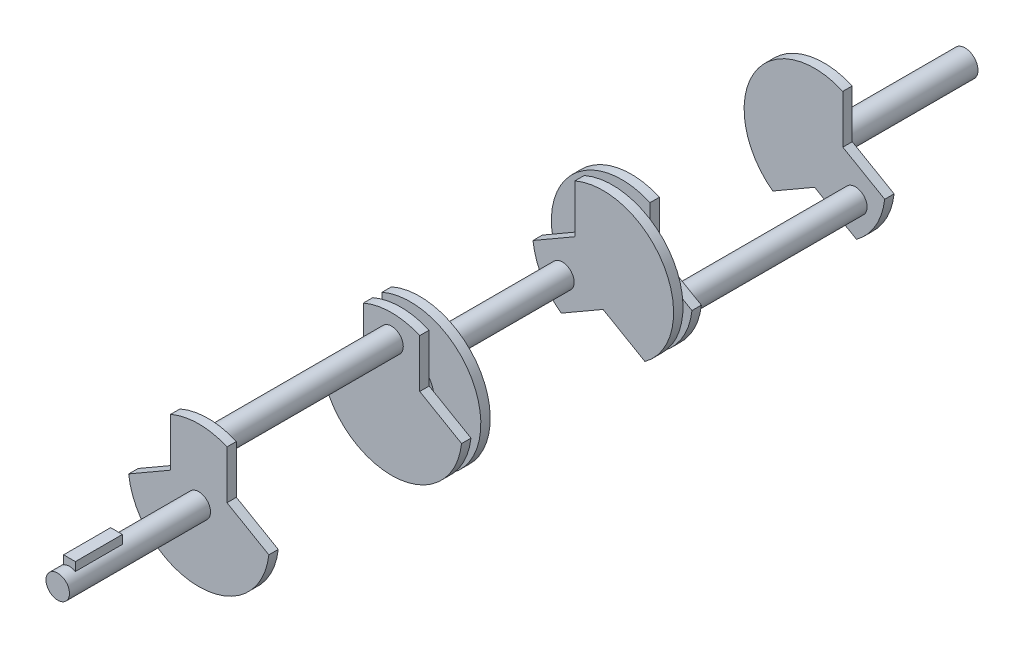
from build123d import *

# Parameters (mm, degrees)
BOSS_EXTRUDE1_DEPTH   = 5.08
LPATTERN1_COUNT       = 2
LPATTERN1_PITCH       = 104.14
SKETCH2_R             = 6.35
BOSS_EXTRUDE2_DEPTH   = 104.14
LPATTERN2_COUNT       = 3
LPATTERN2_PITCH       = 114.3
BODY_MOVE_COPY1_ANGLE = 120
BODY_MOVE_COPY2_ANGLE = 120
SKETCH3_R             = 12.7
BOSS_EXTRUDE3_DEPTH   = 5.08
BOSS_EXTRUDE4_START   = 114.3
SKETCH3_2_R           = 12.7
BOSS_EXTRUDE4_DEPTH   = 5.08
SKETCH4_R             = 6.985
BOSS_EXTRUDE5_DEPTH   = 76.2
SKETCH5_R             = 6.35
BOSS_EXTRUDE6_DEPTH   = 76.2
BOSS_EXTRUDE7_START   = 5.499261
SKETCH6_W             = 6.35
SKETCH6_H             = 25.4
BOSS_EXTRUDE7_DEPTH   = 4.660739


with BuildPart() as part:
    # Sketch1 → Boss-Extrude1 (new body)
    with BuildSketch(Plane.XY):
        with BuildLine():
            Line((15.24, 8.798818102), (15.24, 34.919226796))
            ThreePointArc((15.24, 34.919226796), (0, 38.1), (-15.24, 34.919226796))
            Line((-15.24, 34.919226796), (-15.24, 8.798818102))
            Line((-15.24, 8.798818102), (-37.860937485, -4.261386244))
            ThreePointArc((-37.860937485, -4.261386244), (0, -38.1), (37.860937485, -4.261386244))
            Line((37.860937485, -4.261386244), (15.24, 8.798818102))
        make_face()
    extrude(amount=-BOSS_EXTRUDE1_DEPTH)


with BuildPart() as lpattern1_1:
    # LPattern1: pattern copy
    add(part.part.moved(Location(Vector(0, 0, -1) * (1 * LPATTERN1_PITCH))))


with BuildPart() as part_1:
    add(part.part)

    add(lpattern1_1.part)  # Boss-Extrude2 merges LPattern1_1
    # Sketch2 → Boss-Extrude2 (add)
    with BuildSketch(Plane(origin=(0, 0, -5.08), x_dir=(-1, 0, 0), z_dir=(0, 0, -1))):
        with Locations((0, 25.4)):
            Circle(SKETCH2_R)
    extrude(amount=BOSS_EXTRUDE2_DEPTH)


with BuildPart() as lpattern2_1:
    # LPattern2: pattern copy
    add(part_1.part.moved(Location(Vector(0, 0, -1) * (1 * LPATTERN2_PITCH))))


with BuildPart() as lpattern2_2:
    # LPattern2: pattern copy
    add(part_1.part.moved(Location(Vector(0, 0, -1) * (2 * LPATTERN2_PITCH))))


with BuildPart() as lpattern2_1_1:
    # Body-Move_Copy1: moved
    add(lpattern2_1.part.rotate(Axis((0, 0, 0), (0, 0, 1)), BODY_MOVE_COPY1_ANGLE))


with BuildPart() as lpattern2_2_1:
    # Body-Move_Copy2: moved
    add(lpattern2_2.part.rotate(Axis((0, 0, 0), (0, 0, -1)), BODY_MOVE_COPY2_ANGLE))


with BuildPart() as part_2:
    add(part_1.part)

    add(lpattern2_1_1.part)  # Boss-Extrude3 merges LPattern2_1
    # Sketch3 → Boss-Extrude3 (add)
    with BuildSketch(Plane(origin=(0, 0, -109.22), x_dir=(-1, 0, 0), z_dir=(0, 0, -1))):
        Circle(SKETCH3_R)
    extrude(amount=BOSS_EXTRUDE3_DEPTH)

    add(lpattern2_2_1.part)  # Boss-Extrude4 merges LPattern2_2
    # Sketch3_2 → Boss-Extrude4 (add)
    with BuildSketch(Plane(origin=(0, 0, -109.22), x_dir=(-1, 0, 0), z_dir=(0, 0, -1)).offset(BOSS_EXTRUDE4_START)):
        Circle(SKETCH3_2_R)
    extrude(amount=BOSS_EXTRUDE4_DEPTH)

    # Sketch4 → Boss-Extrude5 (add)
    with BuildSketch(Plane(origin=(0, 0, -337.82), x_dir=(-1, 0, 0), z_dir=(0, 0, -1))):
        Circle(SKETCH4_R)
    extrude(amount=BOSS_EXTRUDE5_DEPTH)

    # Sketch5 → Boss-Extrude6 (add)
    with BuildSketch(Plane.XY):
        Circle(SKETCH5_R)
    extrude(amount=BOSS_EXTRUDE6_DEPTH)

    # Sketch6 → Boss-Extrude7 (add)
    with BuildSketch(Plane(origin=(0, 0, 0), x_dir=(1, 0, 0), z_dir=(0, 1, 0)).offset(BOSS_EXTRUDE7_START)):
        with Locations((0, -57.15)):
            Rectangle(SKETCH6_W, SKETCH6_H)
    extrude(amount=BOSS_EXTRUDE7_DEPTH)


solid = part_2.part
